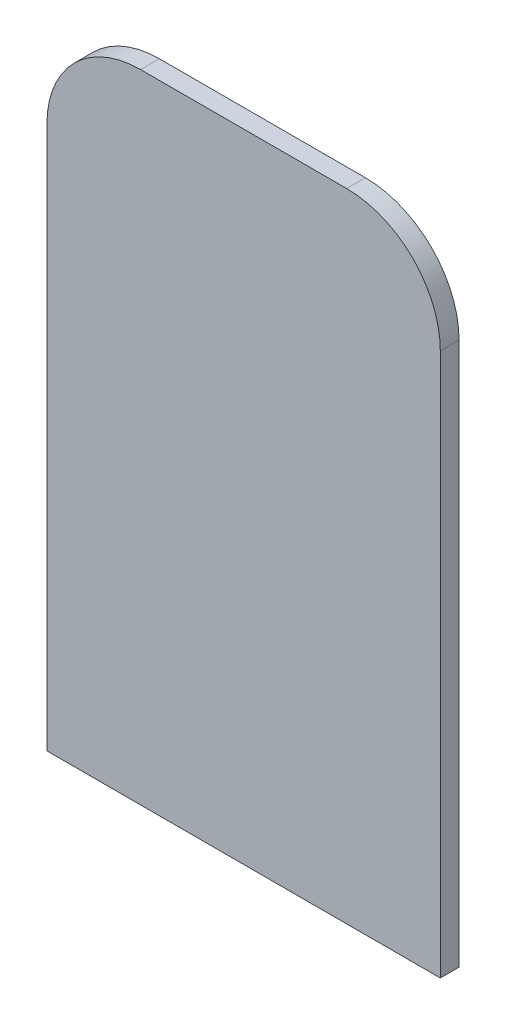
from build123d import *

# Parameters (mm, degrees)
EXTRUDE_1_DEPTH = 1


with BuildPart() as part:
    # 草图1 → 凸台-拉伸1 (new body)
    with BuildSketch(Plane.XY):
        with BuildLine():
            Line((10.5, 0), (-10.5, 0))
            Line((-10.5, 0), (-10.5, 29))
            ThreePointArc((-10.5, 29), (-9.035533906, 32.535533906), (-5.5, 34))
            Line((-5.5, 34), (5.5, 34))
            ThreePointArc((5.5, 34), (9.035533906, 32.535533906), (10.5, 29))
            Line((10.5, 29), (10.5, 0))
        make_face()
    extrude(amount=EXTRUDE_1_DEPTH)


solid = part.part
